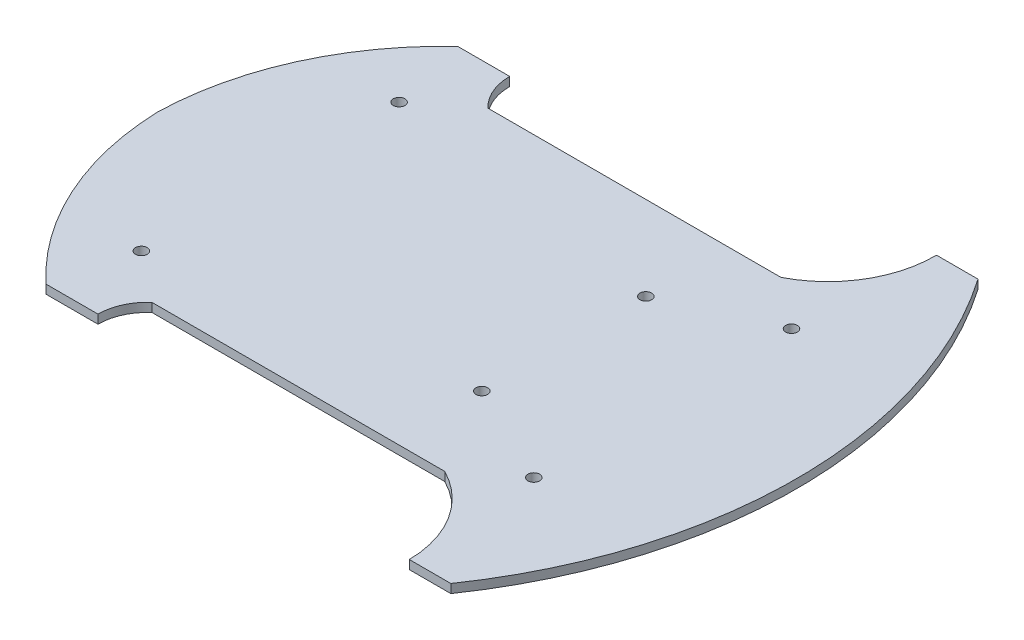
from build123d import *

# Parameters (mm, degrees)
SKETCH3_R           = 2
BOSS_EXTRUDE3_DEPTH = 3


with BuildPart() as part:
    # Sketch3 → Boss-Extrude3 (new body)
    with BuildSketch(Plane(origin=(0, 0, 0), x_dir=(1, 0, 0), z_dir=(0, 1, 0))):
        with BuildLine():
            Line((-49.171013104, 56.877731278), (50.828986896, 56.877731278))
            ThreePointArc((50.828986896, 56.877731278), (65.565194963, 70.579032512), (70.828986896, 90))
            Line((70.828986896, 90), (85, 90))
            ThreePointArc((85, 90), (113.045378517, 0), (85, -90))
            Line((85, -90), (70.825442188, -90))
            ThreePointArc((70.825442188, -90), (65.296898803, -71.164130385), (50.828986896, -57.896338511))
            Line((50.828986896, -57.896338511), (-49.171013104, -57.896338511))
            ThreePointArc((-49.171013104, -57.896338511), (-53.39689903, -63.623937963), (-54.893799534, -70.582586985))
            Line((-54.893799534, -70.582586985), (-72.612335341, -70.582586985))
            ThreePointArc((-72.612335341, -70.582586985), (-95.56056104, -38.735568001), (-104.48280247, -0.509303616))
            ThreePointArc((-104.48280247, -0.509303616), (-95.643665217, 37.952810082), (-72.612335341, 70))
            Line((-72.612335341, 70), (-54.893799534, 70))
            ThreePointArc((-54.893799534, 70), (-53.400865269, 62.84206348), (-49.171013104, 56.877731278))
        make_face()
        with Locations((33.401757754, -27.820969354)):
            Circle(SKETCH3_R, mode=Mode.SUBTRACT)
        with Locations((33.401757754, 28.179030646)):
            Circle(SKETCH3_R, mode=Mode.SUBTRACT)
        with Locations((-66.171013104, 43.490696384)):
            Circle(SKETCH3_R, mode=Mode.SUBTRACT)
        with Locations((67.828986896, 43.490696384)):
            Circle(SKETCH3_R, mode=Mode.SUBTRACT)
        with Locations((67.828986896, -44.509303616)):
            Circle(SKETCH3_R, mode=Mode.SUBTRACT)
        with Locations((-66.171013104, -44.509303616)):
            Circle(SKETCH3_R, mode=Mode.SUBTRACT)
    extrude(amount=BOSS_EXTRUDE3_DEPTH)


solid = part.part
